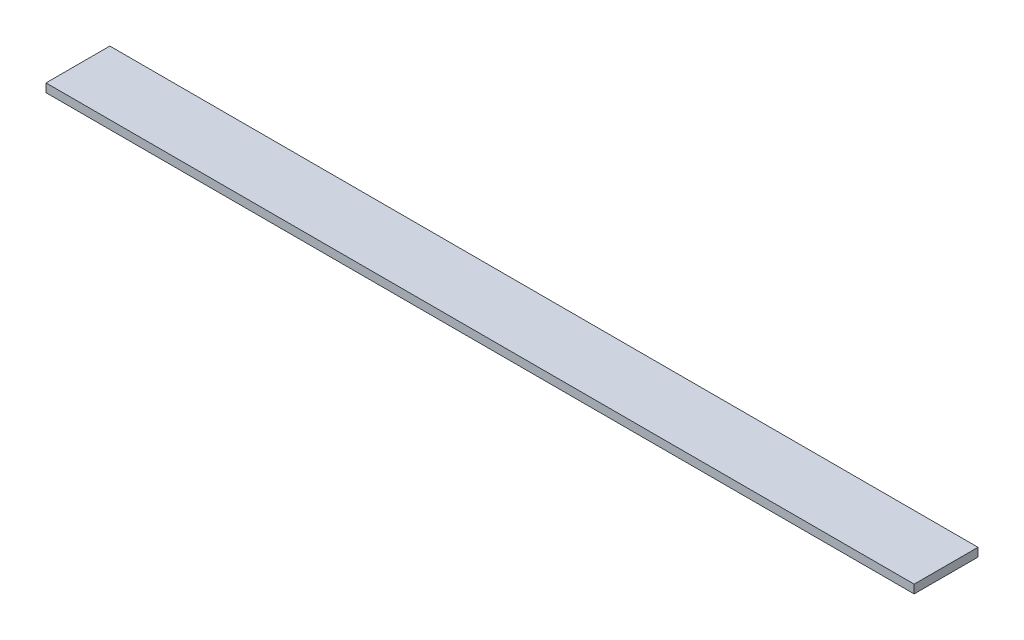
from build123d import *

# Parameters (mm, degrees)
SKETCH_1_W      = 30
SKETCH_1_H      = 4
EXTRUDE_1_DEPTH = 408


with BuildPart() as part:
    # Эскиз1 → Бобышка-Вытянуть1 (new body)
    with BuildSketch(Plane(origin=(0, 0, 0), x_dir=(0, 0, -1), z_dir=(1, 0, 0))):
        Rectangle(SKETCH_1_W, SKETCH_1_H)
    extrude(amount=EXTRUDE_1_DEPTH)


solid = part.part
